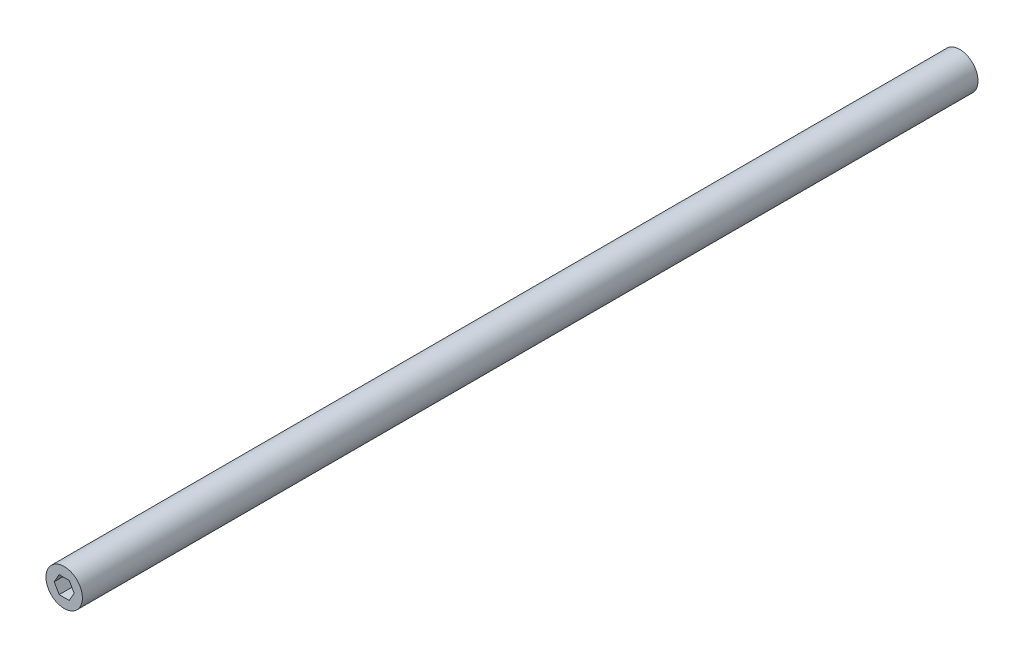
from build123d import *

# Parameters (mm, degrees)
SKETCH2_R           = 12.658951853
BOSS_EXTRUDE4_DEPTH = 622.3


with BuildPart() as part:
    # Sketch2 → Boss-Extrude4 (new body)
    with BuildSketch(Plane.XY):
        with Locations((-46.573237559, 9.77124788)):
            Circle(SKETCH2_R)
        Polygon((-43.103074761, 15.798372741), (-50.057799401, 15.790059449), (-53.5279622, 9.762934589), (-50.043400358, 3.744123019), (-43.088675718, 3.752436311), (-39.618512919, 9.779561172), align=None, mode=Mode.SUBTRACT)
    extrude(amount=BOSS_EXTRUDE4_DEPTH)


solid = part.part
